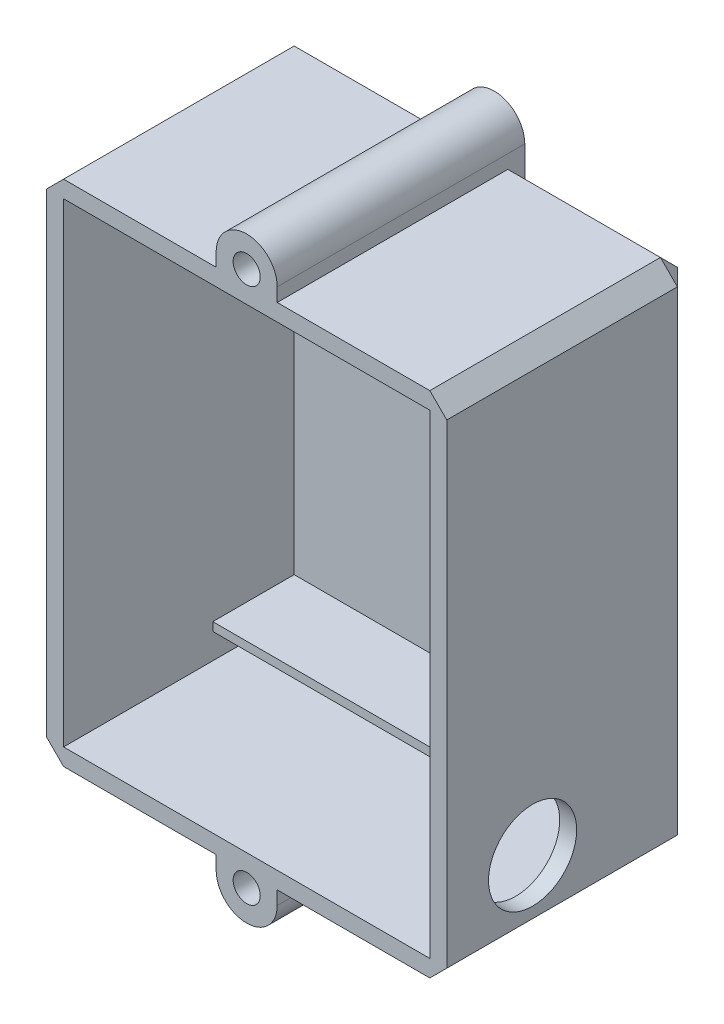
from build123d import *

# Parameters (mm, degrees)
SKETCH1_R           = 2.54
BOSS_EXTRUDE1_DEPTH = 3.175
SKETCH1_3_W         = 13.97
SKETCH1_3_H         = 1.5875
BOSS_EXTRUDE2_DEPTH = 10.16
BOSS_EXTRUDE3_START = 43.18
SKETCH1_4_R         = 2.54
BOSS_EXTRUDE3_DEPTH = 43.18
SKETCH2_W           = 13.97
SKETCH2_H           = 1.5875
BOSS_EXTRUDE4_DEPTH = 15.24
SKETCH3_R           = 8.255
CUT_EXTRUDE1_DEPTH  = 15.24
CHAMFER1_SIZE       = 3.175


with BuildPart() as part:
    # Sketch1 → Boss-Extrude1 (new body)
    with BuildSketch(Plane.XY):
        with BuildLine():
            Line((0, 0), (31.75, 0))
            Line((31.75, 0), (31.75, -2.54))
            ThreePointArc((31.75, -2.54), (37.465, -8.255), (43.18, -2.54))
            Line((43.18, -2.54), (43.18, 0))
            Line((43.18, 0), (74.93, 0))
            Line((74.93, 0), (74.93, 95.25))
            Line((74.93, 95.25), (43.18, 95.25))
            Line((43.18, 95.25), (43.18, 97.79))
            ThreePointArc((43.18, 97.79), (37.465, 103.505), (31.75, 97.79))
            Line((31.75, 97.79), (31.75, 95.25))
            Line((31.75, 95.25), (0, 95.25))
            Line((0, 95.25), (0, 0))
        make_face()
        with Locations((37.465, -2.54)):
            Circle(SKETCH1_R, mode=Mode.SUBTRACT)
        with Locations((37.465, 97.79)):
            Circle(SKETCH1_R, mode=Mode.SUBTRACT)
    extrude(amount=-BOSS_EXTRUDE1_DEPTH)

    # Sketch1_3 → Boss-Extrude2 (add)
    with BuildSketch(Plane.XY):
        Polygon((43.815, 9.525), (43.815, 75.5015), (29.845, 75.5015), (29.845, 77.089), (43.815, 77.089), (45.4025, 77.089), (45.4025, 3.175), (43.815, 3.175), (43.815, 7.9375), (3.175, 7.9375), (3.175, 9.525), align=None)
        with Locations((10.16, 76.29525)):
            Rectangle(SKETCH1_3_W, SKETCH1_3_H)
    extrude(amount=BOSS_EXTRUDE2_DEPTH)

    # Sketch1_4 → Boss-Extrude3 (add)
    with BuildSketch(Plane.XY.offset(BOSS_EXTRUDE3_START)):
        with BuildLine():
            Line((0, 95.25), (0, 0))
            Line((0, 0), (31.75, 0))
            Line((31.75, 0), (31.75, -2.54))
            ThreePointArc((31.75, -2.54), (37.465, -8.255), (43.18, -2.54))
            Line((43.18, -2.54), (43.18, 0))
            Line((43.18, 0), (74.93, 0))
            Line((74.93, 0), (74.93, 95.25))
            Line((74.93, 95.25), (43.18, 95.25))
            Line((43.18, 95.25), (43.18, 97.79))
            ThreePointArc((43.18, 97.79), (37.465, 103.505), (31.75, 97.79))
            Line((31.75, 97.79), (31.75, 95.25))
            Line((31.75, 95.25), (0, 95.25))
        make_face()
        with Locations((37.465, -2.54)):
            Circle(SKETCH1_4_R, mode=Mode.SUBTRACT)
        Polygon((3.175, 7.9375), (3.175, 9.525), (3.175, 75.5015), (3.175, 77.089), (3.175, 92.075), (71.755, 92.075), (71.755, 3.175), (45.4025, 3.175), (43.815, 3.175), (3.175, 3.175), align=None, mode=Mode.SUBTRACT)
        with Locations((37.465, 97.79)):
            Circle(SKETCH1_4_R, mode=Mode.SUBTRACT)
    extrude(amount=-BOSS_EXTRUDE3_DEPTH)

    # Sketch2 → Boss-Extrude4 (add)
    with BuildSketch(Plane.XY):
        with Locations((10.16, 82.20075)):
            Rectangle(SKETCH2_W, SKETCH2_H)
        Polygon((54.737, 82.9945), (55.740027204, 82.9945), (55.740027204, 52.60975), (54.152527204, 52.60975), (54.152527204, 81.407), (29.845, 81.407), (29.845, 82.9945), align=None)
        Polygon((54.152527204, 3.175), (55.740027204, 3.175), (55.740027204, 33.55975), (54.152527204, 33.55975), (54.152527204, 9.525), (3.175, 9.525), (3.175, 7.9375), (54.152527204, 7.9375), align=None)
    extrude(amount=BOSS_EXTRUDE4_DEPTH)

    # Sketch3 → Cut-Extrude1 (cut)
    with BuildSketch(Plane.ZY.offset(-71.755)):
        with Locations((27.1145, 13.462)):
            Circle(SKETCH3_R)
    extrude(amount=-CUT_EXTRUDE1_DEPTH, mode=Mode.SUBTRACT)

    # Chamfer1
    chamfer1_edges = [part.edges().sort_by_distance(p)[0] for p in [
        (74.93, 0, 20.0025),
        (74.93, 95.25, 20.0025),
        (59.055, 95.25, -3.175),
        (74.93, 47.625, -3.175),
        (59.055, 0, -3.175),
        (0, 0, 20.0025),
        (0, 95.25, 20.0025),
        (15.875, 95.25, -3.175),
        (15.875, 0, -3.175),
        (0, 47.625, -3.175),
    ]]
    chamfer(chamfer1_edges, length=CHAMFER1_SIZE)


solid = part.part
